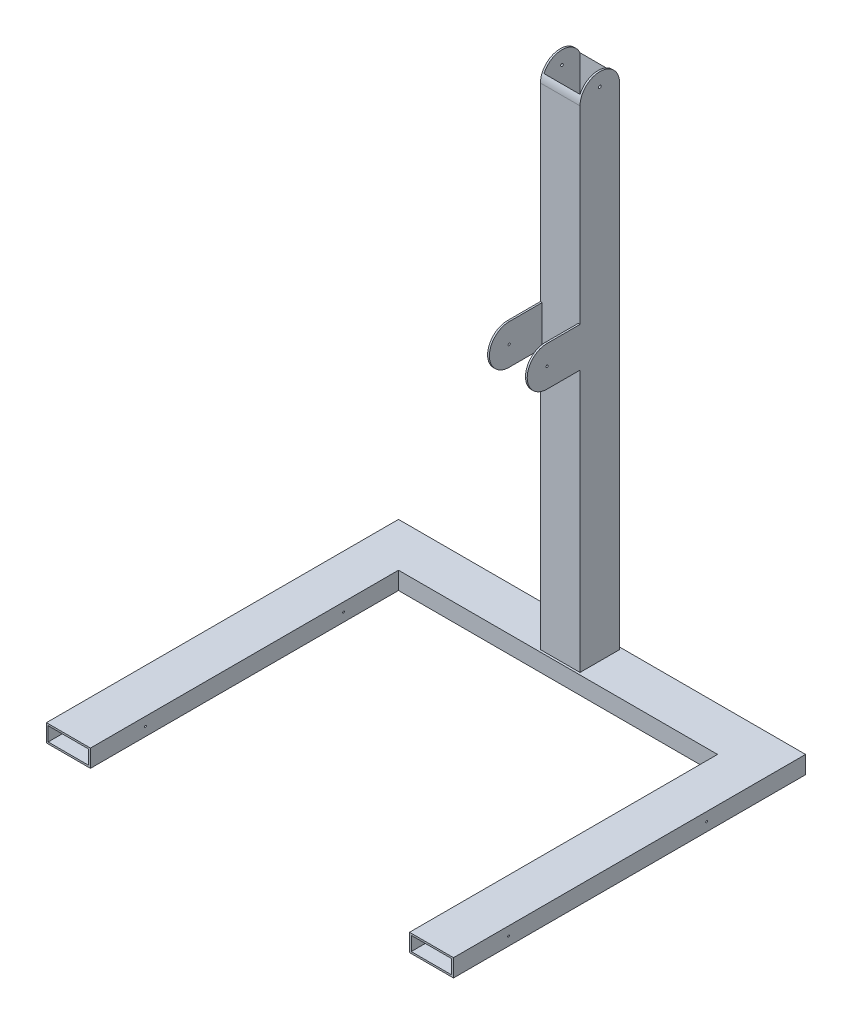
from build123d import *

# Parameters (mm, degrees)
IZIM1_W                       = 200
IZIM1_H                       = 80
IZIM1_W_2                     = 184
IZIM1_H_2                     = 64
Y_KSEKLIK_EKSTR_ZYON1_DEPTH   = 1600
Y_KSEKLIK_EKSTR_ZYON1_2_DEPTH = 1600
IZIM2_W                       = 200
IZIM2_H                       = 80
IZIM2_W_2                     = 184
IZIM2_H_2                     = 64
Y_KSEKLIK_EKSTR_ZYON2_DEPTH   = 1450
IZIM3_W                       = 180
IZIM3_H                       = 180
IZIM3_W_2                     = 164
IZIM3_H_2                     = 164
Y_KSEKLIK_EKSTR_ZYON3_DEPTH   = 2320
KES_EKSTR_ZYON1_DEPTH         = 180
IZIM4_3_R                     = 6
KES_EKSTR_ZYON2_DEPTH         = 180
IZIM5_R                       = 4
KES_EKSTR_ZYON3_DEPTH         = 1850
Y_KSEKLIK_EKSTR_ZYON4_DEPTH   = 8
Y_KSEKLIK_EKSTR_ZYON5_DEPTH   = 8
IZIM8_R                       = 5
KES_EKSTR_ZYON4_DEPTH         = 284


with BuildPart() as part:
    # Çizim1 → Yükseklik-Ekstrüzyon1 (new body)
    with BuildSketch(Plane.XY):
        with Locations((-825, 12.952230465)):
            Rectangle(IZIM1_W, IZIM1_H)
        with Locations((-825, 12.952230465)):
            Rectangle(IZIM1_W_2, IZIM1_H_2, mode=Mode.SUBTRACT)
    extrude(amount=-Y_KSEKLIK_EKSTR_ZYON1_DEPTH)



with BuildPart() as body_2:
    # Çizim1 → Y_kseklik-Ekstr_zyon1 2 (new body)
    with BuildSketch(Plane.XY):
        with Locations((825, 12.952230465)):
            Rectangle(IZIM1_W, IZIM1_H)
        with Locations((825, 12.952230465)):
            Rectangle(IZIM1_W_2, IZIM1_H_2, mode=Mode.SUBTRACT)
    extrude(amount=-Y_KSEKLIK_EKSTR_ZYON1_2_DEPTH)


with BuildPart() as part_1:
    add(part.part)

    add(body_2.part)  # Yükseklik-Ekstrüzyon2 merges body 2
    # Çizim2 → Yükseklik-Ekstrüzyon2 (add)
    with BuildSketch(Plane(origin=(-725, 0, 0), x_dir=(0, 0, -1), z_dir=(1, 0, 0))):
        with Locations((1500, 12.952230465)):
            Rectangle(IZIM2_W, IZIM2_H)
        with Locations((1500, 12.952230465)):
            Rectangle(IZIM2_W_2, IZIM2_H_2, mode=Mode.SUBTRACT)
    extrude(amount=Y_KSEKLIK_EKSTR_ZYON2_DEPTH)

    # Çizim3 → Yükseklik-Ekstrüzyon3 (add)
    with BuildSketch(Plane(origin=(0, 52.952230465, 0), x_dir=(1, 0, 0), z_dir=(0, 1, 0))):
        with Locations((0, 1500)):
            Rectangle(IZIM3_W, IZIM3_H)
        with Locations((0, 1500)):
            Rectangle(IZIM3_W_2, IZIM3_H_2, mode=Mode.SUBTRACT)
    extrude(amount=Y_KSEKLIK_EKSTR_ZYON3_DEPTH)

    # Çizim4 → Kes-Ekstrüzyon1 (cut)
    with BuildSketch(Plane.ZY.offset(90)):
        with BuildLine():
            Line((-1590, 2372.952230465), (-1590, 2282.952230465))
            ThreePointArc((-1590, 2282.952230465), (-1563.639610307, 2346.591840772), (-1500, 2372.952230465))
            Line((-1500, 2372.952230465), (-1590, 2372.952230465))
        make_face()
        with BuildLine():
            ThreePointArc((-1500, 2372.952230465), (-1436.360389693, 2346.591840772), (-1410, 2282.952230465))
            Line((-1410, 2282.952230465), (-1410, 2372.952230465))
            Line((-1410, 2372.952230465), (-1500, 2372.952230465))
        make_face()
    extrude(amount=-KES_EKSTR_ZYON1_DEPTH, mode=Mode.SUBTRACT)

    # Çizim4<3> → Kes-Ekstrüzyon2 (cut)
    with BuildSketch(Plane.ZY.offset(90)):
        with Locations((-1500, 2312.952230465)):
            Circle(IZIM4_3_R)
    extrude(amount=-KES_EKSTR_ZYON2_DEPTH, mode=Mode.SUBTRACT)

    # Çizim5 → Kes-Ekstrüzyon3 (cut)
    with BuildSketch(Plane.ZY.offset(925)):
        with Locations((-250, 12.952230465)):
            Circle(IZIM5_R)
        with Locations((-1150, 12.952230465)):
            Circle(IZIM5_R)
    extrude(amount=-KES_EKSTR_ZYON3_DEPTH, mode=Mode.SUBTRACT)

    # Çizim6 → Yükseklik-Ekstrüzyon4 (add)
    with BuildSketch(Plane.ZY.offset(90)):
        with BuildLine():
            Line((-1410, 1422.952230465), (-1260, 1422.952230465))
            ThreePointArc((-1260, 1422.952230465), (-1170, 1332.952230465), (-1260, 1242.952230465))
            Line((-1260, 1242.952230465), (-1410, 1242.952230465))
            Line((-1410, 1242.952230465), (-1410, 1422.952230465))
        make_face()
    extrude(amount=-Y_KSEKLIK_EKSTR_ZYON4_DEPTH)

    # Çizim7 → Yükseklik-Ekstrüzyon5 (add)
    with BuildSketch(Plane(origin=(90, 0, 0), x_dir=(0, 0, -1), z_dir=(1, 0, 0))):
        with BuildLine():
            Line((1410, 1422.952230465), (1260, 1422.952230465))
            ThreePointArc((1260, 1422.952230465), (1170, 1332.952230465), (1260, 1242.952230465))
            Line((1260, 1242.952230465), (1410, 1242.952230465))
            Line((1410, 1242.952230465), (1410, 1422.952230465))
        make_face()
    extrude(amount=-Y_KSEKLIK_EKSTR_ZYON5_DEPTH)

    # Çizim8 → Kes-Ekstrüzyon4 (cut)
    with BuildSketch(Plane.ZY.offset(90)):
        with Locations((-1260, 1332.952230465)):
            Circle(IZIM8_R)
    extrude(amount=-KES_EKSTR_ZYON4_DEPTH, mode=Mode.SUBTRACT)


solid = part_1.part
